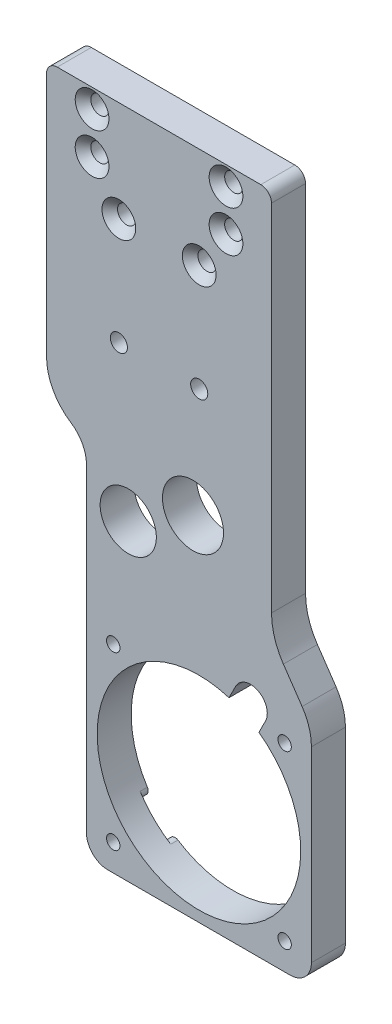
from build123d import *

# Parameters (mm, degrees)
BOSS_EXTRUDE1_DEPTH                             = 6.35
SKETCH2_R                                       = 19
CUT_EXTRUDE1_DEPTH                              = 101.601052339
M3X0_5_TAPPED_HOLE1_D                           = 2.5
F_3_2_3_2_DIAMETER_HOLE2_D                      = 3.2
F_3_2_3_2_DIAMETER_HOLE2_DEPTH                  = 9.53
CSK_FOR_M3_FLAT_HEAD_MACHINE_SCREW1_D           = 3.4
CSK_FOR_M3_FLAT_HEAD_MACHINE_SCREW1_CSINK_D     = 6.3
CSK_FOR_M3_FLAT_HEAD_MACHINE_SCREW1_CSINK_ANGLE = 90
CSK_FOR_M3_FLAT_HEAD_MACHINE_SCREW2_D           = 3.4
CSK_FOR_M3_FLAT_HEAD_MACHINE_SCREW2_CSINK_D     = 6.3
CSK_FOR_M3_FLAT_HEAD_MACHINE_SCREW2_CSINK_ANGLE = 90
M12X1_5_TAPPED_HOLE4_D                          = 10.5
SKETCH42_R                                      = 5.7
CUT_EXTRUDE11_DEPTH                             = 101.601052339
CUT_EXTRUDE6_DEPTH                              = 101.601052339
SKETCH40_R                                      = 4.25
CUT_EXTRUDE9_DEPTH                              = 101.524868723
FILLET7_R                                       = 1
CIRPATTERN1_COUNT                               = 4
FILLET7_OF_CIRPATTERN1_R                        = 1
CUT_EXTRUDE10_DEPTH                             = 101.524868852
CUT_EXTRUDE8_DEPTH                              = 120.475402348
FILLET3_R                                       = 12.7
FILLET1_R                                       = 4
FILLET4_R                                       = 2
FILLET5_R                                       = 10
FILLET6_R                                       = 10
SKETCH48_W                                      = 1.221153846
SKETCH48_H                                      = 0.325641026
SKETCH48_W_2                                    = 2.27948718
SKETCH48_H_2                                    = 0.203525641
CUT_EXTRUDE16_DEPTH                             = 0.2
CUT_EXTRUDE17_DEPTH                             = 101.601052469


with BuildPart() as part:
    # Sketch1 → Boss-Extrude1 (new body)
    with BuildSketch(Plane.XY):
        Polygon((-13.55, -96.285236312), (28.45, -96.285236312), (28.45, -54.285236312), (28.45, -41.381457796), (21, -41.381457796), (21, 28.8), (-21, 28.8), (-21, -41.381457796), (-21, -54.285236312), (-13.55, -54.285236312), align=None)
    extrude(amount=BOSS_EXTRUDE1_DEPTH)

    # Sketch2 → Cut-Extrude1 (cut, through all)
    with BuildSketch(Plane.XY.offset(6.35)):
        with Locations((7.45, -75.285236312)):
            Circle(SKETCH2_R)
    extrude(amount=-CUT_EXTRUDE1_DEPTH, mode=Mode.SUBTRACT)

    # M3x0.5 Tapped Hole1 (through all)
    with Locations(Plane.XY.offset(6.35)):
        with Locations((-8.55, -59.285236312), (23.45, -91.285236312), (-8.55, -91.285236312), (23.45, -59.285236312)):
            Hole(M3X0_5_TAPPED_HOLE1_D / 2)

    # Ø3.2 (3.2) Diameter Hole2
    with Locations(Plane.XY.offset(6.35)):
        with Locations((7.5, -10), (-7.5, -10)):
            Hole(F_3_2_3_2_DIAMETER_HOLE2_D / 2, depth=F_3_2_3_2_DIAMETER_HOLE2_DEPTH)

    # CSK for M3 Flat Head Machine Screw1 (through all)
    with Locations(Plane.XY.offset(6.35)):
        with Locations((-7.5, 10), (7.5, 10)):
            CounterSinkHole(CSK_FOR_M3_FLAT_HEAD_MACHINE_SCREW1_D / 2, CSK_FOR_M3_FLAT_HEAD_MACHINE_SCREW1_CSINK_D / 2, counter_sink_angle=CSK_FOR_M3_FLAT_HEAD_MACHINE_SCREW1_CSINK_ANGLE)

    # CSK for M3 Flat Head Machine Screw2 (through all)
    with Locations(Plane.XY.offset(6.35)):
        with Locations((-12.5, 17.55), (-12.5, 25.24), (12.5, 17.55), (12.5, 25.24)):
            CounterSinkHole(CSK_FOR_M3_FLAT_HEAD_MACHINE_SCREW2_D / 2, CSK_FOR_M3_FLAT_HEAD_MACHINE_SCREW2_CSINK_D / 2, counter_sink_angle=CSK_FOR_M3_FLAT_HEAD_MACHINE_SCREW2_CSINK_ANGLE)

    # M12x1.5 Tapped Hole4 (through all)
    with Locations(Plane.XY.offset(6.35)):
        with Locations((-5.75, -38)):
            Hole(M12X1_5_TAPPED_HOLE4_D / 2)

    # Sketch42 → Cut-Extrude11 (cut, through all)
    with BuildSketch(Plane.XY.offset(6.35)):
        with Locations((6.331054383, -31.025)):
            Circle(SKETCH42_R)
    extrude(amount=-CUT_EXTRUDE11_DEPTH, mode=Mode.SUBTRACT)

    # Sketch31 → Cut-Extrude6 (cut, through all)
    with BuildSketch(Plane.XY.offset(6.35)):
        with BuildLine():
            Line((-13.55, -32.75), (-13.55, -54.285236312))
            Line((-13.55, -54.285236312), (-21, -54.285236312))
            Line((-21, -54.285236312), (-21, -26.4))
            Line((-21, -26.4), (-19.9, -26.4))
            ThreePointArc((-19.9, -26.4), (-15.409871939, -28.259871939), (-13.55, -32.75))
        make_face()
    extrude(amount=-CUT_EXTRUDE6_DEPTH, mode=Mode.SUBTRACT)

    # Sketch40 → Cut-Extrude9 (cut, through all)
    with BuildSketch(Plane.XY.offset(1.35)):
        with Locations((-8.55, -59.285236312)):
            Circle(SKETCH40_R)
    cut_extrude9 = extrude(amount=-CUT_EXTRUDE9_DEPTH, mode=Mode.SUBTRACT)

    # Fillet7
    fillet7_edges = [part.edges().sort_by_distance(p)[0] for p in [
        (-4.475502354, -60.493941792, 0.675),
        (-7.341294521, -63.359733958, 0.675),
    ]]
    fillet(fillet7_edges, radius=FILLET7_R)

    # CirPattern1: Cut-Extrude9 ×4 about axis
    cirpattern1_axis = Axis((7.45, -75.285236312, 0), (0, 0, 1))
    for i in range(1, CIRPATTERN1_COUNT):
        add(cut_extrude9.rotate(cirpattern1_axis, i * 360 / CIRPATTERN1_COUNT), mode=Mode.SUBTRACT)

    # Fillet7 of CirPattern1
    fillet7_of_cirpattern1_edges = [part.edges().sort_by_distance(p)[0] for p in [
        (-7.341294521, -87.210738667, 0.675),
        (-4.475502354, -90.076530833, 0.675),
        (19.375502354, -90.076530833, 0.675),
        (22.241294521, -87.210738667, 0.675),
        (22.241294521, -63.359733958, 0.675),
        (19.375502354, -60.493941792, 0.675),
    ]]
    fillet(fillet7_of_cirpattern1_edges, radius=FILLET7_OF_CIRPATTERN1_R)

    # Sketch41 → Cut-Extrude10 (cut, through all)
    with BuildSketch(Plane.XY.offset(1.35)):
        Polygon((-4.35262985, -58.61846512), (-5.322562328, -52.512673984), (-15.322562328, -52.512673984), (-15.322562328, -62.512673984), (-9.216771192, -63.482606462), align=None)
    extrude(amount=-CUT_EXTRUDE10_DEPTH, mode=Mode.SUBTRACT)


with BuildPart() as body_2:
    # Body-Move_Copy2: copy of part
    add(part.part.moved(Location((42, 0, 0))))


with BuildPart() as part_1:
    add(part.part)

    # Sketch37 → Cut-Extrude8 (cut, through all)
    with BuildSketch(Plane.XY.offset(6.35)):
        Polygon((21, -43.381457796), (21, -41.381457796), (28.45, -41.381457796), (28.45, -54.285236312), align=None)
    extrude(amount=-CUT_EXTRUDE8_DEPTH, mode=Mode.SUBTRACT)

    # Fillet3
    fillet3_edges = [part_1.edges().sort_by_distance(p)[0] for p in [
        (21, -43.381457796, 3.175),
    ]]
    fillet(fillet3_edges, radius=FILLET3_R)

    # Fillet1
    fillet1_edges = [part_1.edges().sort_by_distance(p)[0] for p in [
        (-13.55, -96.285236312, 3.175),
        (28.45, -96.285236312, 3.175),
    ]]
    fillet(fillet1_edges, radius=FILLET1_R)

    # Fillet4
    fillet4_edges = [part_1.edges().sort_by_distance(p)[0] for p in [
        (-21, 28.8, 3.175),
        (21, 28.8, 3.175),
    ]]
    fillet(fillet4_edges, radius=FILLET4_R)

    # Fillet5
    fillet5_edges = [part_1.edges().sort_by_distance(p)[0] for p in [
        (-21, -26.4, 3.175),
    ]]
    fillet(fillet5_edges, radius=FILLET5_R)

    # Fillet6
    fillet6_edges = [part_1.edges().sort_by_distance(p)[0] for p in [
        (28.45, -54.285236312, 3.175),
    ]]
    fillet(fillet6_edges, radius=FILLET6_R)

    # Sketch48 → Cut-Extrude16 (cut)
    # profile 1 of 11: a face of its own
    with BuildSketch(Plane(origin=(0, 0, 0), x_dir=(-1, 0, 0), z_dir=(0, 0, -1))):
        with BuildLine():
            Line((-10.039289149, -17.596374014), (-10.324225046, -17.596374014))
            add(Edge.make_bspline(
                [(-10.324225046, -17.596374014), (-10.322367986, -17.558572566), (-10.318720769, -17.484331528), (-10.301640821, -17.376087698), (-10.277201597, -17.272623702), (-10.242647206, -17.17477028), (-10.199733654, -17.081662219), (-10.148271415, -16.993669348), (-10.087316994, -16.911127341), (-10.018186599, -16.834801391), (-9.94310362, -16.764781237), (-9.862090375, -16.70431541), (-9.776959528, -16.653227236), (-9.687969359, -16.610517824), (-9.594115848, -16.578459535), (-9.496250684, -16.554672762), (-9.393943896, -16.540361363), (-9.324239019, -16.538823043), (-9.288788348, -16.538040681)],
                knots=[0, 0, 0, 0, 1.10065271, 2.161652631, 3.183658789, 4.190468796, 5.17591951, 6.163126047, 7.15150782, 8.156236427, 9.156009102, 10.134482811, 11.092018607, 12.041330605, 13.001268258, 13.972401359, 14.968799086, 16, 16, 16, 16], degree=3))
            add(Edge.make_bspline(
                [(-9.288788348, -16.538040681), (-9.253973952, -16.538855709), (-9.185564908, -16.540457211), (-9.085722938, -16.55421043), (-8.990674963, -16.575751074), (-8.900606775, -16.605972916), (-8.816236988, -16.646598789), (-8.736931798, -16.695400842), (-8.661747062, -16.751843118), (-8.594068051, -16.818294791), (-8.531921436, -16.889235526), (-8.478307248, -16.964970981), (-8.432393878, -17.043193262), (-8.394123626, -17.124498845), (-8.365951271, -17.209653278), (-8.344562468, -17.297416812), (-8.3324726, -17.38869789), (-8.330617109, -17.450480266), (-8.329673764, -17.481890841)],
                knots=[0, 0, 0, 0, 1.111607364, 2.184268762, 3.212621178, 4.221274766, 5.211760367, 6.196651075, 7.1921475, 8.207485113, 9.220403448, 10.201281604, 11.166441695, 12.114753415, 13.065576456, 14.026450734, 14.996634279, 16, 16, 16, 16], degree=3))
            add(Edge.make_bspline(
                [(-8.329673764, -17.481890841), (-8.331209796, -17.526112091), (-8.334254903, -17.61377857), (-8.360302945, -17.742606339), (-8.400985137, -17.867423226), (-8.449968453, -17.967877779), (-8.499382742, -18.048825305), (-8.543912124, -18.115471916), (-8.596040917, -18.187231877), (-8.65652784, -18.26386489), (-8.72412166, -18.345971211), (-8.799434622, -18.43350124), (-8.883003781, -18.525550631), (-8.941658278, -18.588420712), (-8.972051569, -18.620998413)],
                knots=[0, 0, 0, 0, 1.184426356, 2.348067706, 3.509069118, 4.696110526, 5.333549288, 6.050745305, 6.844228056, 7.710549037, 8.667450064, 9.695053472, 10.805634456, 12, 12, 12, 12], degree=3))
            Line((-8.972051569, -18.620998413), (-9.766437586, -19.468809912))
            Line((-9.766437586, -19.468809912), (-8.288968636, -19.468809912))
            Line((-8.288968636, -19.468809912), (-8.288968636, -19.794450937))
            Line((-8.288968636, -19.794450937), (-10.446340431, -19.794450937))
            Line((-10.446340431, -19.794450937), (-9.215010303, -18.480438517))
            add(Edge.make_bspline(
                [(-9.215010303, -18.480438517), (-9.185031148, -18.449143625), (-9.127447328, -18.389032541), (-9.046001705, -18.301272856), (-8.972850623, -18.219857201), (-8.907520559, -18.144939404), (-8.851428736, -18.075423624), (-8.801651783, -18.013561286), (-8.761768711, -17.956634035), (-8.718484031, -17.890647906), (-8.676561348, -17.810082447), (-8.640536568, -17.711626886), (-8.618570241, -17.610274307), (-8.61593514, -17.541783173), (-8.614609662, -17.507331546)],
                knots=[0, 0, 0, 0, 1.329631726, 2.553950428, 3.673215718, 4.687767853, 5.603093632, 6.413772471, 7.123043292, 7.734684054, 8.834405432, 9.900288307, 10.943827018, 12, 12, 12, 12], degree=3))
            add(Edge.make_bspline(
                [(-8.614609662, -17.507331546), (-8.615186371, -17.485667706), (-8.616322954, -17.442972438), (-8.626353865, -17.380374356), (-8.641512681, -17.319990561), (-8.663234451, -17.261635313), (-8.69190628, -17.205895329), (-8.726807131, -17.152702758), (-8.76707526, -17.101277768), (-8.813658198, -17.053060133), (-8.864831505, -17.008899325), (-8.918892003, -16.969779619), (-8.976087454, -16.937086997), (-9.036176708, -16.910286825), (-9.098992241, -16.889263443), (-9.164655545, -16.874696018), (-9.232985189, -16.865549765), (-9.279642717, -16.864312266), (-9.303416753, -16.863681706)],
                knots=[0, 0, 0, 0, 0.991446411, 1.95395049, 2.89581595, 3.838931463, 4.798493298, 5.75982156, 6.748411868, 7.785213223, 8.824556874, 9.840280684, 10.836137867, 11.835679398, 12.848801643, 13.863922112, 14.911575587, 16, 16, 16, 16], degree=3))
            add(Edge.make_bspline(
                [(-9.303416753, -16.863681706), (-9.328246009, -16.864330343), (-9.377006567, -16.865604158), (-9.448597404, -16.874514717), (-9.516892359, -16.889887015), (-9.582063228, -16.91091157), (-9.644220281, -16.937634682), (-9.703061235, -16.970919336), (-9.758453999, -17.010637219), (-9.810502702, -17.055668295), (-9.858457883, -17.105803905), (-9.900591835, -17.161692943), (-9.937407333, -17.222314955), (-9.969528567, -17.287506369), (-9.995614086, -17.357858727), (-10.015546872, -17.433122287), (-10.031319226, -17.512970255), (-10.036588384, -17.56811101), (-10.039289149, -17.596374014)],
                knots=[0, 0, 0, 0, 1.031018746, 2.02475058, 2.990194455, 3.934040569, 4.864654155, 5.795059489, 6.735614925, 7.690564532, 8.649604399, 9.611025574, 10.590972636, 11.591080095, 12.624614302, 13.701020113, 14.821632451, 16, 16, 16, 16], degree=3))
        make_face()
    # profile 2 of 11: a face of its own
    with BuildSketch(Plane(origin=(0, 0, 0), x_dir=(-1, 0, 0), z_dir=(0, 0, -1))):
        with BuildLine():
            Line((-6.009481457, -16.619450937), (-6.009481457, -16.945091963))
            Line((-6.009481457, -16.945091963), (-7.089439389, -16.945091963))
            Line((-7.089439389, -16.945091963), (-7.260528131, -17.780183109))
            add(Edge.make_bspline(
                [(-7.260528131, -17.780183109), (-7.22691316, -17.770902791), (-7.161789468, -17.752923642), (-7.065668737, -17.732961265), (-6.974417238, -17.720927612), (-6.915203152, -17.719284495), (-6.886549766, -17.718489399)],
                knots=[0, 0, 0, 0, 1.100273476, 2.13160584, 3.095893838, 4, 4, 4, 4], degree=3))
            add(Edge.make_bspline(
                [(-6.886549766, -17.718489399), (-6.851095231, -17.719256783), (-6.781382756, -17.720765653), (-6.679384568, -17.735254402), (-6.582018301, -17.758059896), (-6.489487579, -17.789919226), (-6.401621223, -17.83065877), (-6.319227649, -17.88154943), (-6.241070114, -17.940997524), (-6.168550761, -18.009346213), (-6.102760853, -18.084567965), (-6.04491599, -18.165446891), (-5.995782784, -18.251196985), (-5.956266956, -18.342637537), (-5.924712596, -18.438757626), (-5.903710429, -18.540568612), (-5.889725271, -18.647110835), (-5.888162821, -18.719958552), (-5.887366072, -18.757106186)],
                knots=[0, 0, 0, 0, 1.052922333, 2.070308379, 3.05430497, 4.020497103, 4.973039431, 5.925935799, 6.892292201, 7.88610001, 8.88166317, 9.857072816, 10.836096531, 11.812156883, 12.81219415, 13.836441305, 14.89672472, 16, 16, 16, 16], degree=3))
            add(Edge.make_bspline(
                [(-5.887366072, -18.757106186), (-5.88796939, -18.782979914), (-5.889167874, -18.83437771), (-5.895262592, -18.91070852), (-5.906997135, -18.985423376), (-5.922752142, -19.058532189), (-5.943201335, -19.129896548), (-5.967956405, -19.19972072), (-5.998251373, -19.267570113), (-6.031481264, -19.334086721), (-6.068897712, -19.397766796), (-6.110425358, -19.457319805), (-6.154299767, -19.513639117), (-6.201508739, -19.566120718), (-6.25249107, -19.614419741), (-6.306629325, -19.658822825), (-6.363491506, -19.700080889), (-6.423957333, -19.736519181), (-6.486679443, -19.770049862), (-6.552563611, -19.797557642), (-6.620110104, -19.822150764), (-6.690291098, -19.841753693), (-6.762947628, -19.857113939), (-6.83819946, -19.867546627), (-6.915651925, -19.875145252), (-6.968152829, -19.875620919), (-6.994672763, -19.875861194)],
                knots=[0, 0, 0, 0, 1.056347294, 2.098418968, 3.122841568, 4.141288669, 5.149314143, 6.15115421, 7.162517403, 8.180376062, 9.185164535, 10.17417709, 11.141909838, 12.097768115, 13.052685741, 14.0056014, 14.954263652, 15.917497458, 16.885230207, 17.854509472, 18.828990115, 19.81800267, 20.826176721, 21.857883937, 22.917946725, 24, 24, 24, 24], degree=3))
            add(Edge.make_bspline(
                [(-6.994672763, -19.875861194), (-7.026308627, -19.875234505), (-7.088548452, -19.874001569), (-7.179734966, -19.861103371), (-7.26746893, -19.84263039), (-7.351044093, -19.814838917), (-7.431209454, -19.780016157), (-7.506885776, -19.736005058), (-7.58000673, -19.686131157), (-7.647599792, -19.627275408), (-7.710334266, -19.562944754), (-7.766492314, -19.493133179), (-7.816506344, -19.4189929), (-7.859575443, -19.34016386), (-7.896312934, -19.256853192), (-7.925173673, -19.168748756), (-7.94846761, -19.076310895), (-7.958322284, -19.012671639), (-7.963327611, -18.980348373)],
                knots=[0, 0, 0, 0, 1.0467383, 2.05933395, 3.04377827, 4.011590433, 4.970194871, 5.932262533, 6.905835911, 7.896367577, 8.894135286, 9.877477877, 10.858688626, 11.851381753, 12.8477658, 13.868841284, 14.917554742, 16, 16, 16, 16], degree=3))
            Line((-7.963327611, -18.980348373), (-7.678391713, -18.980348373))
            add(Edge.make_bspline(
                [(-7.678391713, -18.980348373), (-7.671380807, -19.010625583), (-7.657905458, -19.068820063), (-7.628327385, -19.150582066), (-7.592163341, -19.223443076), (-7.549160825, -19.288366912), (-7.497861869, -19.344980788), (-7.439324458, -19.395433408), (-7.373694738, -19.440949419), (-7.300766594, -19.478888643), (-7.223829015, -19.511245298), (-7.143304475, -19.532791478), (-7.061385532, -19.547941574), (-7.005978724, -19.5494581), (-6.978136304, -19.550220168)],
                knots=[0, 0, 0, 0, 1.136247022, 2.183929868, 3.172523383, 4.106158343, 5.02341133, 5.958108904, 6.928429099, 7.938127109, 8.96079061, 9.975095812, 10.982467395, 12, 12, 12, 12], degree=3))
            add(Edge.make_bspline(
                [(-6.978136304, -19.550220168), (-6.950959716, -19.549475605), (-6.89744879, -19.548009555), (-6.81869846, -19.536725594), (-6.74266821, -19.51934694), (-6.670108251, -19.493339286), (-6.599748854, -19.461730148), (-6.533369791, -19.421167187), (-6.469050753, -19.374485599), (-6.408790946, -19.321003513), (-6.353600874, -19.262066718), (-6.304836393, -19.199040797), (-6.264217335, -19.131806229), (-6.229987108, -19.061527012), (-6.203994473, -18.987432892), (-6.185451583, -18.909871112), (-6.174563093, -18.828650094), (-6.173065237, -18.773251506), (-6.172301969, -18.745021851)],
                knots=[0, 0, 0, 0, 1.027316725, 2.022795036, 3.002884548, 3.971462791, 4.93288096, 5.914575861, 6.907176829, 7.935150275, 8.956128384, 9.956726525, 10.942570165, 11.921478529, 12.907843606, 13.90538589, 14.932640048, 16, 16, 16, 16], degree=3))
            add(Edge.make_bspline(
                [(-6.172301969, -18.745021851), (-6.172899304, -18.719553133), (-6.174068503, -18.669701742), (-6.183621234, -18.596768176), (-6.200237345, -18.527759059), (-6.223300436, -18.462341147), (-6.252582561, -18.400452739), (-6.288366001, -18.342029963), (-6.331322298, -18.287842843), (-6.380391368, -18.237866026), (-6.434146877, -18.191742461), (-6.493513701, -18.152423183), (-6.557249491, -18.1193452), (-6.624586342, -18.09079923), (-6.697125929, -18.070297126), (-6.773431731, -18.054904829), (-6.854327745, -18.046000893), (-6.909636869, -18.044765466), (-6.938067194, -18.044130424)],
                knots=[0, 0, 0, 0, 1.045622112, 2.046656509, 3.013763289, 3.955457236, 4.890082067, 5.820317437, 6.762574623, 7.722996705, 8.69280354, 9.665887285, 10.63943826, 11.638615906, 12.663482002, 13.728887084, 14.832589034, 16, 16, 16, 16], degree=3))
            add(Edge.make_bspline(
                [(-6.938067194, -18.044130424), (-6.962677008, -18.044657103), (-7.01349003, -18.045744562), (-7.091434309, -18.053751456), (-7.1733418, -18.06666853), (-7.258898521, -18.084436054), (-7.348361411, -18.107687103), (-7.441541674, -18.135549543), (-7.53863523, -18.168861641), (-7.604056309, -18.194018721), (-7.637686585, -18.206950937)],
                knots=[0, 0, 0, 0, 0.817624296, 1.688186739, 2.600797293, 3.572016777, 4.590301741, 5.671205678, 6.80286297, 8, 8, 8, 8], degree=3))
            Line((-7.637686585, -18.206950937), (-7.312045559, -16.619450937))
            Line((-7.312045559, -16.619450937), (-6.009481457, -16.619450937))
        make_face()
    # profile 3 of 11: a face of its own
    with BuildSketch(Plane(origin=(0, 0, 0), x_dir=(-1, 0, 0), z_dir=(0, 0, -1))):
        Polygon((-4.886910343, -16.619450937), (-4.299866072, -16.619450937), (-4.299866072, -19.794450937), (-4.584801969, -19.794450937), (-4.584801969, -16.945091963), (-5.073263508, -16.945091963), align=None)
    # profile 4 of 11: a face of its own
    with BuildSketch(Plane(origin=(0, 0, 0), x_dir=(-1, 0, 0), z_dir=(0, 0, -1))):
        with BuildLine():
            Line((-1.654032739, -16.538040681), (-1.434606657, -16.710401458))
            Line((-1.434606657, -16.710401458), (-2.273513909, -17.993249014))
            add(Edge.make_bspline(
                [(-2.273513909, -17.993249014), (-2.217660872, -17.98434644), (-2.108713208, -17.966980964), (-1.998435571, -17.964116256), (-1.944692795, -17.962720168)],
                knots=[0, 0, 0, 0, 1.025318673, 2, 2, 2, 2], degree=3))
            add(Edge.make_bspline(
                [(-1.944692795, -17.962720168), (-1.912423459, -17.963587498), (-1.848902231, -17.965294811), (-1.755641775, -17.978433733), (-1.666026097, -17.99913937), (-1.580426635, -18.029322059), (-1.498536144, -18.067877766), (-1.419884685, -18.114086599), (-1.345950719, -18.170334609), (-1.275782149, -18.233167819), (-1.212076139, -18.302761083), (-1.155673574, -18.376603724), (-1.108296413, -18.454618809), (-1.069857213, -18.536766823), (-1.040007787, -18.622921137), (-1.018247567, -18.712971521), (-1.00538465, -18.80698007), (-1.003637955, -18.870913843), (-1.002750687, -18.90339024)],
                knots=[0, 0, 0, 0, 1.04369286, 2.054478336, 3.041073146, 4.015093852, 4.984733326, 5.965804835, 6.960378782, 7.985147595, 9.009457201, 10.008161701, 10.986880575, 11.956520048, 12.937015923, 13.931873656, 14.949455224, 16, 16, 16, 16], degree=3))
            add(Edge.make_bspline(
                [(-1.002750687, -18.90339024), (-1.004041647, -18.947821829), (-1.00658195, -19.03525268), (-1.031894679, -19.162594406), (-1.071228071, -19.283908903), (-1.127450543, -19.39725928), (-1.197284562, -19.502490182), (-1.282444949, -19.595731283), (-1.379911542, -19.678889102), (-1.490117424, -19.748427607), (-1.60871997, -19.805217517), (-1.733317853, -19.846007416), (-1.86270105, -19.871120277), (-1.950516659, -19.874268609), (-1.994938187, -19.875861194)],
                knots=[0, 0, 0, 0, 1.031375318, 2.029502543, 3.004789286, 3.987476834, 4.960371455, 5.9300674, 6.912260825, 7.929083631, 8.949397511, 9.960523116, 10.96833055, 12, 12, 12, 12], degree=3))
            add(Edge.make_bspline(
                [(-1.994938187, -19.875861194), (-2.037661623, -19.874474893), (-2.122289269, -19.871728873), (-2.246779018, -19.847266915), (-2.366397612, -19.807618329), (-2.480306979, -19.752995377), (-2.585826392, -19.684000011), (-2.680228791, -19.600939944), (-2.763043472, -19.505590643), (-2.831963307, -19.3979669), (-2.886626585, -19.282315295), (-2.927620303, -19.161722304), (-2.951565466, -19.03662732), (-2.954911514, -18.951826572), (-2.956596841, -18.909114399)],
                knots=[0, 0, 0, 0, 1.012016664, 2.004627821, 2.994792927, 3.992885782, 4.990978636, 5.973936114, 6.964471063, 7.975201453, 8.993600317, 9.990122807, 10.98767138, 12, 12, 12, 12], degree=3))
            add(Edge.make_bspline(
                [(-2.956596841, -18.909114399), (-2.955525102, -18.876416812), (-2.953336815, -18.809654589), (-2.938057454, -18.708540792), (-2.913505818, -18.605080168), (-2.886010095, -18.517310292), (-2.856958291, -18.445408769), (-2.832780631, -18.387439174), (-2.802687077, -18.327784486), (-2.770598367, -18.264399116), (-2.733626064, -18.198916616), (-2.69342544, -18.130242573), (-2.648885042, -18.059469168), (-2.617661037, -18.011441219), (-2.601699005, -17.986888838)],
                knots=[0, 0, 0, 0, 1.173818275, 2.396712641, 3.66331629, 4.989737886, 5.693666774, 6.447286557, 7.243889047, 8.091586357, 8.998013824, 9.943181721, 10.948533338, 12, 12, 12, 12], degree=3))
            Line((-2.601699005, -17.986888838), (-1.654032739, -16.538040681))
        make_face()
        with BuildLine():
            add(Edge.make_bspline(
                [(-2.004478452, -18.288361194), (-2.028664917, -18.28906699), (-2.075908109, -18.290445616), (-2.145220549, -18.298451381), (-2.210818999, -18.313527247), (-2.273572542, -18.332728134), (-2.332307958, -18.359128767), (-2.38745212, -18.391197899), (-2.439218274, -18.428954253), (-2.48706421, -18.471862937), (-2.530443476, -18.518842081), (-2.567800645, -18.569160862), (-2.600024536, -18.621606603), (-2.626224472, -18.676617508), (-2.646626184, -18.734172547), (-2.661383811, -18.794007009), (-2.669596857, -18.856522129), (-2.670963224, -18.898915186), (-2.671660944, -18.920562716)],
                knots=[0, 0, 0, 0, 1.129588631, 2.206414736, 3.251139165, 4.268635594, 5.265702196, 6.250456724, 7.242448911, 8.251968645, 9.246821453, 10.222880186, 11.173611482, 12.116736599, 13.062300278, 14.020270554, 14.989073742, 16, 16, 16, 16], degree=3))
            add(Edge.make_bspline(
                [(-2.671660944, -18.920562716), (-2.671092745, -18.942016626), (-2.66997859, -18.984084551), (-2.659861843, -19.046077949), (-2.64440859, -19.105736116), (-2.621421231, -19.162751495), (-2.594001125, -19.217993155), (-2.557801295, -19.269460164), (-2.517690354, -19.32027837), (-2.469744285, -19.366543991), (-2.418288092, -19.409593928), (-2.363314144, -19.447222444), (-2.306019037, -19.479413473), (-2.245629247, -19.504642111), (-2.18300157, -19.525347), (-2.117614211, -19.539917056), (-2.049421692, -19.548154391), (-2.003228219, -19.549522538), (-1.979673764, -19.550220168)],
                knots=[0, 0, 0, 0, 0.989467248, 1.94019797, 2.891935182, 3.827694429, 4.772920941, 5.730924762, 6.725747692, 7.756678648, 8.79901574, 9.819492441, 10.826891316, 11.826466727, 12.835195252, 13.867842842, 14.912794438, 16, 16, 16, 16], degree=3))
            add(Edge.make_bspline(
                [(-1.979673764, -19.550220168), (-1.956119348, -19.549522483), (-1.909925951, -19.548154229), (-1.841732884, -19.539917672), (-1.776347552, -19.525344741), (-1.713712505, -19.5046503), (-1.653349921, -19.479383097), (-1.596104923, -19.447422712), (-1.541650867, -19.40936252), (-1.490160895, -19.36661756), (-1.442414393, -19.320015044), (-1.401341433, -19.269913796), (-1.366250215, -19.217577191), (-1.337734916, -19.162969105), (-1.315000745, -19.105701642), (-1.299469128, -19.046087185), (-1.289373273, -18.984082133), (-1.288256248, -18.94201581), (-1.287686585, -18.920562716)],
                knots=[0, 0, 0, 0, 1.087397944, 2.132534446, 3.165364764, 4.174271784, 5.174024072, 6.181601208, 7.194203697, 8.236725232, 9.267838612, 10.269026844, 11.221737037, 12.171628256, 13.107553087, 14.05945871, 15.010357665, 16, 16, 16, 16], degree=3))
            add(Edge.make_bspline(
                [(-1.287686585, -18.920562716), (-1.288185779, -18.898886945), (-1.289165535, -18.856344455), (-1.300247146, -18.794034973), (-1.315616299, -18.733868536), (-1.338823763, -18.676223282), (-1.368974057, -18.621326691), (-1.405698291, -18.568901453), (-1.448182122, -18.518545638), (-1.497256319, -18.471770805), (-1.550678174, -18.42900167), (-1.607479455, -18.391246786), (-1.666904545, -18.359383415), (-1.728893193, -18.332797686), (-1.794155665, -18.313612092), (-1.86163833, -18.298505221), (-1.932204286, -18.290466105), (-1.980080209, -18.289071768), (-2.004478452, -18.288361194)],
                knots=[0, 0, 0, 0, 0.978206639, 1.919901502, 2.851605144, 3.780102724, 4.718870031, 5.675451981, 6.667674623, 7.690630536, 8.733308323, 9.756129687, 10.767539656, 11.776269907, 12.797430371, 13.836405707, 14.897401972, 16, 16, 16, 16], degree=3))
        make_face(mode=Mode.SUBTRACT)
    # profile 5 of 11: a face of its own
    with BuildSketch(Plane(origin=(0, 0, 0), x_dir=(-1, 0, 0), z_dir=(0, 0, -1))):
        with Locations((-0.066532739, -18.573297091)):
            Rectangle(SKETCH48_W, SKETCH48_H)
    # profile 6 of 11: a face of its own
    with BuildSketch(Plane(origin=(0, 0, 0), x_dir=(-1, 0, 0), z_dir=(0, 0, -1))):
        Polygon((1.463089657, -16.619450937), (2.050133928, -16.619450937), (2.050133928, -19.794450937), (1.765198031, -19.794450937), (1.765198031, -16.945091963), (1.276736492, -16.945091963), align=None)
    # profile 7 of 11: a face of its own
    with BuildSketch(Plane(origin=(0, 0, 0), x_dir=(-1, 0, 0), z_dir=(0, 0, -1))):
        with Locations((4.207505723, -20.221854783)):
            Rectangle(SKETCH48_W_2, SKETCH48_H_2)
    # profile 8 of 11: a face of its own
    with BuildSketch(Plane(origin=(0, 0, 0), x_dir=(-1, 0, 0), z_dir=(0, 0, -1))):
        with BuildLine():
            Line((5.713595466, -16.619450937), (6.348977077, -16.619450937))
            add(Edge.make_bspline(
                [(6.348977077, -16.619450937), (6.391377958, -16.619592076), (6.472792346, -16.619863078), (6.58942667, -16.621374163), (6.695405536, -16.625705185), (6.790673533, -16.629432258), (6.875228913, -16.636228519), (6.949330956, -16.642724249), (7.012638367, -16.651227498), (7.050961389, -16.65912456), (7.068313014, -16.662700136)],
                knots=[0, 0, 0, 0, 1.410062039, 2.707475311, 3.878576406, 4.937260626, 5.877586885, 6.699081471, 7.410979367, 8, 8, 8, 8], degree=3))
            add(Edge.make_bspline(
                [(7.068313014, -16.662700136), (7.091541881, -16.668439416), (7.137504078, -16.679795541), (7.20368021, -16.703798179), (7.266739632, -16.731574553), (7.326420401, -16.764198785), (7.382423583, -16.80191305), (7.435326622, -16.844066275), (7.485369578, -16.890427812), (7.530528629, -16.942166561), (7.573109054, -16.996446823), (7.609021594, -17.055142374), (7.639979186, -17.116521045), (7.664626727, -17.18120706), (7.684473174, -17.248573096), (7.698466977, -17.319229361), (7.706859126, -17.39285396), (7.707713523, -17.443071492), (7.708146748, -17.468534471)],
                knots=[0, 0, 0, 0, 1.027469482, 2.033020251, 3.019912614, 3.986113645, 4.951240523, 5.91722682, 6.890402269, 7.87763091, 8.8651537, 9.85103654, 10.82876324, 11.815024772, 12.821070561, 13.842952187, 14.906261191, 16, 16, 16, 16], degree=3))
            add(Edge.make_bspline(
                [(7.708146748, -17.468534471), (7.706814157, -17.510839173), (7.704213927, -17.593386604), (7.67997044, -17.713184689), (7.640258883, -17.824934996), (7.585537042, -17.928496817), (7.515850803, -18.021851474), (7.432099029, -18.10384853), (7.334234995, -18.172464737), (7.243131259, -18.220046924), (7.162654806, -18.250520491), (7.096403158, -18.271962045), (7.024133828, -18.288528256), (6.946539246, -18.303369233), (6.863296502, -18.314573984), (6.774605109, -18.322780538), (6.680401814, -18.327909568), (6.615687087, -18.328673386), (6.582395547, -18.329066322)],
                knots=[0, 0, 0, 0, 1.260483769, 2.459530307, 3.627416485, 4.787058657, 5.939039949, 7.08810263, 8.267026773, 9.491475466, 10.141966685, 10.831826277, 11.566392101, 12.351337768, 13.187381173, 14.07005841, 15.007169909, 16, 16, 16, 16], degree=3))
            Line((6.582395547, -18.329066322), (7.748851877, -19.794450937))
            Line((7.748851877, -19.794450937), (7.396498111, -19.794450937))
            Line((7.396498111, -19.794450937), (6.230041781, -18.329066322))
            Line((6.230041781, -18.329066322), (5.998531364, -18.329066322))
            Line((5.998531364, -18.329066322), (5.998531364, -19.794450937))
            Line((5.998531364, -19.794450937), (5.713595466, -19.794450937))
            Line((5.713595466, -19.794450937), (5.713595466, -16.619450937))
        make_face()
        with BuildLine():
            Line((5.998531364, -16.945091963), (5.998531364, -18.003425296))
            Line((5.998531364, -18.003425296), (6.579851476, -18.00787742))
            add(Edge.make_bspline(
                [(6.579851476, -18.00787742), (6.606993226, -18.007889427), (6.659601667, -18.007912701), (6.735711556, -18.004289775), (6.806577657, -18.000168337), (6.871928911, -17.993864288), (6.931794511, -17.985739851), (6.986144536, -17.975577144), (7.035067704, -17.963737059), (7.092125664, -17.945411298), (7.155840232, -17.916377267), (7.225083771, -17.874135708), (7.284050177, -17.82100515), (7.333868524, -17.760250657), (7.373900222, -17.69345206), (7.4021233, -17.621410068), (7.420032515, -17.545943404), (7.422144839, -17.494074692), (7.423210851, -17.467898453)],
                knots=[0, 0, 0, 0, 1.146690395, 2.22261258, 3.21895312, 4.145990853, 4.996080663, 5.770904154, 6.481378293, 7.121626537, 8.300444488, 9.431385265, 10.535395872, 11.636531494, 12.74115979, 13.810798291, 14.895190096, 16, 16, 16, 16], degree=3))
            add(Edge.make_bspline(
                [(7.423210851, -17.467898453), (7.422120355, -17.44236549), (7.419959391, -17.391768473), (7.40231658, -17.317694898), (7.372481212, -17.247784164), (7.332274611, -17.182320667), (7.283289663, -17.122897607), (7.225851362, -17.072054832), (7.16153022, -17.030099961), (7.101412776, -17.003289915), (7.047678883, -16.98685262), (7.001024835, -16.975285493), (6.948309423, -16.965992296), (6.889276685, -16.958546412), (6.824178634, -16.95214657), (6.752686115, -16.947836028), (6.675273464, -16.945283451), (6.621618748, -16.945157278), (6.593843864, -16.945091963)],
                knots=[0, 0, 0, 0, 1.101028733, 2.181837193, 3.264309656, 4.369019818, 5.486613113, 6.575447106, 7.666700264, 8.788928104, 9.402425223, 10.0903467, 10.862060571, 11.710948788, 12.657782767, 13.684531032, 14.801375019, 16, 16, 16, 16], degree=3))
            Line((6.593843864, -16.945091963), (5.998531364, -16.945091963))
        make_face(mode=Mode.SUBTRACT)
    # profile 9 of 11: a face of its own
    with BuildSketch(Plane(origin=(0, 0, 0), x_dir=(-1, 0, 0), z_dir=(0, 0, -1))):
        with BuildLine():
            Line((8.522249313, -17.352143245), (8.237313415, -17.352143245))
            add(Edge.make_bspline(
                [(8.237313415, -17.352143245), (8.245032793, -17.320182349), (8.260123546, -17.257701411), (8.291599202, -17.168431967), (8.325888526, -17.08395563), (8.367062928, -17.005854192), (8.411974441, -16.932558044), (8.463430053, -16.865729624), (8.519055801, -16.803669291), (8.580582719, -16.748593711), (8.645106577, -16.698721057), (8.713536553, -16.656198683), (8.784495893, -16.619618916), (8.858476235, -16.58948342), (8.935697833, -16.566781695), (9.015462563, -16.550310879), (9.097979452, -16.539614654), (9.153993338, -16.538570747), (9.182435611, -16.538040681)],
                knots=[0, 0, 0, 0, 1.162005537, 2.271625781, 3.343758855, 4.383309926, 5.390229558, 6.379919256, 7.361854164, 8.333198761, 9.295911338, 10.242430842, 11.177959212, 12.116337295, 13.062827104, 14.020064771, 14.994644689, 16, 16, 16, 16], degree=3))
            add(Edge.make_bspline(
                [(9.182435611, -16.538040681), (9.223876384, -16.53929184), (9.305853987, -16.541766866), (9.426289036, -16.564367819), (9.542427651, -16.600132046), (9.652998611, -16.649547499), (9.755703904, -16.71049599), (9.847086016, -16.78303543), (9.925906308, -16.865766225), (9.992031922, -16.957145051), (10.0438071, -17.054803977), (10.081985453, -17.155315548), (10.105227978, -17.258441337), (10.108240197, -17.328071154), (10.109749313, -17.362955545)],
                knots=[0, 0, 0, 0, 1.083050992, 2.142477498, 3.193116406, 4.255571735, 5.30263384, 6.308962982, 7.297363603, 8.282367274, 9.249857812, 10.179914175, 11.08814088, 12, 12, 12, 12], degree=3))
            add(Edge.make_bspline(
                [(10.109749313, -17.362955545), (10.108693769, -17.396525994), (10.106628235, -17.462218154), (10.089089802, -17.558122655), (10.059574763, -17.648511821), (10.01869005, -17.733766161), (9.96576593, -17.813345123), (9.901655697, -17.887427752), (9.825906854, -17.956342632), (9.768503818, -17.995821011), (9.738951035, -18.016145649)],
                knots=[0, 0, 0, 0, 1.024540389, 2.004866551, 2.965041327, 3.920577974, 4.882998113, 5.874504559, 6.905732034, 8, 8, 8, 8], degree=3))
            add(Edge.make_bspline(
                [(9.738951035, -18.016145649), (9.772725556, -18.032454419), (9.839642649, -18.064766809), (9.930856343, -18.12813596), (10.013658416, -18.20130279), (10.059835361, -18.258400768), (10.083036572, -18.287089158)],
                knots=[0, 0, 0, 0, 1.015518401, 2.012035669, 3.001164323, 4, 4, 4, 4], degree=3))
            add(Edge.make_bspline(
                [(10.083036572, -18.287089158), (10.098314076, -18.308005833), (10.128618903, -18.349496657), (10.166025423, -18.416204701), (10.199960833, -18.483652123), (10.226404247, -18.553646727), (10.246881969, -18.625377247), (10.261519655, -18.698966849), (10.270612983, -18.774475626), (10.271915234, -18.825559091), (10.272569825, -18.851236795)],
                knots=[0, 0, 0, 0, 1.025084078, 2.033381695, 3.024893161, 4.013698104, 4.991890475, 5.976764909, 6.982997093, 8, 8, 8, 8], degree=3))
            add(Edge.make_bspline(
                [(10.272569825, -18.851236795), (10.270941945, -18.895695613), (10.267693846, -18.984404026), (10.238661578, -19.115463238), (10.193655282, -19.243574944), (10.129740775, -19.366107119), (10.051846678, -19.480752179), (9.959175391, -19.583328545), (9.852779863, -19.671501565), (9.734120453, -19.745170843), (9.605562773, -19.804060672), (9.468062057, -19.84493421), (9.323599508, -19.871555224), (9.224532888, -19.874409884), (9.174167381, -19.875861194)],
                knots=[0, 0, 0, 0, 0.955779014, 1.907060117, 2.875433937, 3.871313158, 4.872415639, 5.851225146, 6.836215519, 7.83643374, 8.849228613, 9.86973379, 10.916971861, 12, 12, 12, 12], degree=3))
            add(Edge.make_bspline(
                [(9.174167381, -19.875861194), (9.140222731, -19.8750736), (9.073430977, -19.873523879), (8.97523866, -19.862929719), (8.881511119, -19.843580357), (8.792121626, -19.817542359), (8.706990772, -19.78452985), (8.626378334, -19.743419317), (8.549788359, -19.695058168), (8.477943596, -19.638875557), (8.41085261, -19.576027484), (8.350298353, -19.505398239), (8.295271255, -19.428293452), (8.247244718, -19.343817536), (8.204031197, -19.253062196), (8.168488472, -19.154865344), (8.137205135, -19.050104838), (8.122660492, -18.977100031), (8.115198031, -18.939643245)],
                knots=[0, 0, 0, 0, 1.048658725, 2.063410685, 3.046034179, 4.001477787, 4.936774919, 5.862367409, 6.792675028, 7.730719943, 8.675894397, 9.627829632, 10.600096036, 11.597688215, 12.626045268, 13.701542398, 14.82072376, 16, 16, 16, 16], degree=3))
            Line((8.115198031, -18.939643245), (8.400133928, -18.939643245))
            add(Edge.make_bspline(
                [(8.400133928, -18.939643245), (8.407557342, -18.96408985), (8.421996528, -19.01164062), (8.446574927, -19.080075754), (8.47457686, -19.142811988), (8.504616495, -19.200309534), (8.536165514, -19.253134642), (8.57146691, -19.299890481), (8.607906063, -19.3426307), (8.635373762, -19.366710455), (8.648816821, -19.378495408)],
                knots=[0, 0, 0, 0, 1.198163088, 2.33053128, 3.407730985, 4.417276592, 5.372219308, 6.28897303, 7.162600585, 8, 8, 8, 8], degree=3))
            add(Edge.make_bspline(
                [(8.648816821, -19.378495408), (8.666593715, -19.392200825), (8.702092631, -19.419569354), (8.759939526, -19.454495832), (8.820776958, -19.484759047), (8.885923127, -19.5078764), (8.95397224, -19.527450421), (9.026024207, -19.540259749), (9.101443354, -19.549048304), (9.152939825, -19.549823849), (9.179255522, -19.550220168)],
                knots=[0, 0, 0, 0, 0.946170439, 1.889420265, 2.845303464, 3.807233317, 4.801018734, 5.828864929, 6.890507805, 8, 8, 8, 8], degree=3))
            add(Edge.make_bspline(
                [(9.179255522, -19.550220168), (9.208967628, -19.549661454), (9.267067087, -19.548568937), (9.351843995, -19.538521688), (9.432495751, -19.523889099), (9.508126905, -19.501289465), (9.579728151, -19.473366835), (9.64629579, -19.43830721), (9.708703687, -19.39717307), (9.766152504, -19.35041969), (9.817810215, -19.299237334), (9.863293916, -19.245704048), (9.901960573, -19.190045546), (9.933151391, -19.131953822), (9.957780818, -19.071669435), (9.974547722, -19.009023212), (9.986205882, -18.944527834), (9.987155309, -18.900686555), (9.987633928, -18.878585553)],
                knots=[0, 0, 0, 0, 1.217147791, 2.380027433, 3.494444702, 4.572153297, 5.609568379, 6.639424714, 7.649109417, 8.668170816, 9.669597737, 10.625200337, 11.543417969, 12.441394052, 13.322311151, 14.205496177, 15.095365482, 16, 16, 16, 16], degree=3))
            add(Edge.make_bspline(
                [(9.987633928, -18.878585553), (9.986245726, -18.849002409), (9.983476229, -18.789983325), (9.962332018, -18.703153811), (9.927553191, -18.619494001), (9.878864556, -18.540431249), (9.819595716, -18.467155967), (9.750321836, -18.401776836), (9.670467658, -18.347828968), (9.596971062, -18.310555687), (9.531869813, -18.285122054), (9.476157286, -18.268181193), (9.413785224, -18.253835949), (9.345507893, -18.240489817), (9.270810833, -18.229131165), (9.189775364, -18.219658947), (9.102385066, -18.212079731), (9.041886651, -18.208695094), (9.010710851, -18.206950937)],
                knots=[0, 0, 0, 0, 1.07054697, 2.135767047, 3.216561865, 4.33974944, 5.486079747, 6.621378074, 7.775625952, 8.963672916, 9.598146892, 10.304877434, 11.070270905, 11.915000392, 12.823868403, 13.805723172, 14.86925407, 16, 16, 16, 16], degree=3))
            Line((9.010710851, -18.206950937), (9.010710851, -17.881309912))
            add(Edge.make_bspline(
                [(9.010710851, -17.881309912), (9.049991194, -17.88064334), (9.126931737, -17.879337689), (9.239321571, -17.863546137), (9.34679379, -17.841701567), (9.44696662, -17.808241428), (9.538269381, -17.769379159), (9.617480735, -17.724156083), (9.683490932, -17.673886989), (9.73597919, -17.617795979), (9.775466419, -17.557638758), (9.804337871, -17.494940075), (9.821392453, -17.429150391), (9.823669079, -17.384251657), (9.824813415, -17.361683509)],
                knots=[0, 0, 0, 0, 1.321986639, 2.589447074, 3.816329219, 5.01088745, 6.139805852, 7.153945165, 8.075214402, 8.924034688, 9.728124013, 10.488707548, 11.240355623, 12, 12, 12, 12], degree=3))
            add(Edge.make_bspline(
                [(9.824813415, -17.361683509), (9.824437485, -17.345102983), (9.82368959, -17.312116813), (9.814257774, -17.263924787), (9.800084537, -17.217206071), (9.780599354, -17.172159344), (9.754518817, -17.129097024), (9.723307672, -17.087651981), (9.686143752, -17.048060838), (9.643557525, -17.011157977), (9.597826816, -16.97598874), (9.547707378, -16.94613137), (9.494710391, -16.920599778), (9.438777183, -16.899545444), (9.379726238, -16.883707375), (9.317835003, -16.872335576), (9.252985462, -16.865225704), (9.208742533, -16.864202069), (9.186251716, -16.863681706)],
                knots=[0, 0, 0, 0, 0.884392785, 1.759457502, 2.611959086, 3.489218968, 4.37281399, 5.2945488, 6.255912374, 7.266815255, 8.301784654, 9.332968512, 10.37626691, 11.440494194, 12.520033166, 13.637162961, 14.798855837, 16, 16, 16, 16], degree=3))
            add(Edge.make_bspline(
                [(9.186251716, -16.863681706), (9.15010056, -16.86494387), (9.079488945, -16.867409171), (8.977693984, -16.889001904), (8.883061446, -16.923453451), (8.810727084, -16.964576976), (8.757312177, -17.005172013), (8.719142383, -17.04062532), (8.681658777, -17.080025096), (8.647327342, -17.125798051), (8.612607377, -17.174844353), (8.580998382, -17.229657264), (8.550282804, -17.288806965), (8.531774777, -17.33062229), (8.522249313, -17.352143245)],
                knots=[0, 0, 0, 0, 1.472543308, 2.876219568, 4.221790263, 5.565193594, 6.249813518, 6.953379497, 7.687249741, 8.463570142, 9.283606569, 10.136032583, 11.040678096, 12, 12, 12, 12], degree=3))
        make_face()
    # profile 10 of 11: a face of its own
    with BuildSketch(Plane(origin=(0, 0, 0), x_dir=(-1, 0, 0), z_dir=(0, 0, -1))):
        with BuildLine():
            add(Edge.make_bspline(
                [(11.066319825, -19.305989399), (11.084000232, -19.307040021), (11.118660603, -19.309099644), (11.168770383, -19.323229913), (11.214122682, -19.348320269), (11.25451979, -19.381760075), (11.287817807, -19.422305426), (11.313802327, -19.467296001), (11.327809506, -19.517825303), (11.329854126, -19.552686508), (11.330903159, -19.570572732)],
                knots=[0, 0, 0, 0, 1.020151414, 1.999887582, 2.974338812, 3.990962822, 5.007586832, 5.987933904, 6.967670073, 8, 8, 8, 8], degree=3))
            add(Edge.make_bspline(
                [(11.330903159, -19.570572732), (11.329818578, -19.588029181), (11.327679801, -19.622453043), (11.313834435, -19.672601226), (11.287619775, -19.717619918), (11.25474946, -19.758715429), (11.214112695, -19.792226076), (11.168663163, -19.817102968), (11.118778236, -19.832244978), (11.084019857, -19.834173833), (11.066319825, -19.835156065)],
                knots=[0, 0, 0, 0, 1.009421747, 1.99056486, 2.972319754, 3.999869655, 5.017953583, 5.993804169, 6.978383603, 8, 8, 8, 8], degree=3))
            add(Edge.make_bspline(
                [(11.066319825, -19.835156065), (11.04860704, -19.834209374), (11.014027042, -19.832361183), (10.964328318, -19.816792066), (10.918601997, -19.792459356), (10.877973144, -19.758652945), (10.844827531, -19.717831387), (10.819767362, -19.672291185), (10.804717727, -19.622596596), (10.802738457, -19.588057456), (10.801736492, -19.570572732)],
                knots=[0, 0, 0, 0, 1.022052826, 1.995314843, 2.982371812, 4.00089066, 5.028879526, 6.005146991, 6.990147033, 8, 8, 8, 8], degree=3))
            add(Edge.make_bspline(
                [(10.801736492, -19.570572732), (10.802699968, -19.552657223), (10.804581036, -19.517679391), (10.819798956, -19.467605915), (10.844633091, -19.422095974), (10.878202271, -19.381821933), (10.918592168, -19.348087737), (10.964218011, -19.323536104), (11.014146737, -19.308985158), (11.048627181, -19.307005304), (11.066319825, -19.305989399)],
                knots=[0, 0, 0, 0, 1.032775665, 2.016367738, 2.991239715, 4.008302682, 5.025365648, 6.011011707, 6.979408107, 8, 8, 8, 8], degree=3))
        make_face()
    # profile 11 of 11: a face of its own
    with BuildSketch(Plane(origin=(0, 0, 0), x_dir=(-1, 0, 0), z_dir=(0, 0, -1))):
        Polygon((12.412769144, -16.619450937), (12.999813415, -16.619450937), (12.999813415, -19.794450937), (12.714877518, -19.794450937), (12.714877518, -16.945091963), (12.226415979, -16.945091963), align=None)
    extrude(amount=-CUT_EXTRUDE16_DEPTH, mode=Mode.SUBTRACT)

    # Sketch49 → Cut-Extrude17 (cut, through all)
    with BuildSketch(Plane.XY.offset(6.35)):
        with BuildLine():
            Line((19.874829022, -57.491315334), (17.653624925, -61.918034526))
            ThreePointArc((17.653624925, -61.918034526), (13.459021834, -63.309636088), (12.067420272, -59.115032997))
            Line((12.067420272, -59.115032997), (14.288624368, -54.688313805))
            ThreePointArc((14.288624368, -54.688313805), (18.483227459, -53.296712243), (19.874829022, -57.491315334))
        make_face()
    extrude(amount=-CUT_EXTRUDE17_DEPTH, mode=Mode.SUBTRACT)


solid = part_1.part
